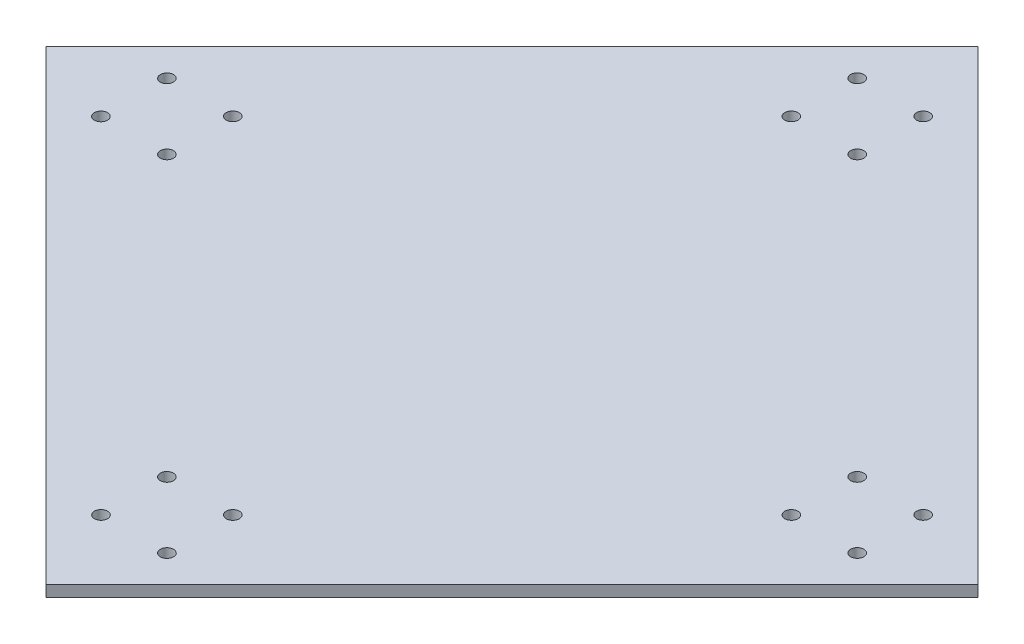
from build123d import *

# Parameters (mm, degrees)
SKETCH3_R           = 1500
BOSS_EXTRUDE2_DEPTH = 2500


with BuildPart() as part:
    # Sketch3 → Boss-Extrude2 (new body)
    with BuildSketch(Plane(origin=(0, 0, 0), x_dir=(1, 0, 0), z_dir=(0, 1, 0))):
        Polygon((94457.392609736, 188109.713508362), (200523.409787719, 82043.696330379), (94472.169284797, -24037.095464325), (-11608.622509908, 82043.696330379), align=None)
        with Locations((23406.152106819, 74543.696330375)):
            Circle(SKETCH3_R, mode=Mode.SUBTRACT)
        with Locations((8406.152106819, 89543.696330375)):
            Circle(SKETCH3_R, mode=Mode.SUBTRACT)
        with Locations((8406.152106819, 74528.921713652)):
            Circle(SKETCH3_R, mode=Mode.SUBTRACT)
        with Locations((101972.169284806, 10977.679152396)):
            Circle(SKETCH3_R, mode=Mode.SUBTRACT)
        with Locations((86972.169284806, -4022.320847604)):
            Circle(SKETCH3_R, mode=Mode.SUBTRACT)
        with Locations((101986.943901529, -4022.320847604)):
            Circle(SKETCH3_R, mode=Mode.SUBTRACT)
        with Locations((165538.186462784, 89543.696330384)):
            Circle(SKETCH3_R, mode=Mode.SUBTRACT)
        with Locations((180538.186462784, 74543.696330384)):
            Circle(SKETCH3_R, mode=Mode.SUBTRACT)
        with Locations((180538.186462784, 89558.470947106)):
            Circle(SKETCH3_R, mode=Mode.SUBTRACT)
        with Locations((23406.152106818, 89543.696330376)):
            Circle(SKETCH3_R, mode=Mode.SUBTRACT)
        with Locations((86972.169284804, 10977.679152397)):
            Circle(SKETCH3_R, mode=Mode.SUBTRACT)
        with Locations((165538.186462783, 74543.696330383)):
            Circle(SKETCH3_R, mode=Mode.SUBTRACT)
        with Locations((86972.169284797, 153109.713508362)):
            Circle(SKETCH3_R, mode=Mode.SUBTRACT)
        with Locations((101972.169284797, 153109.713508362)):
            Circle(SKETCH3_R, mode=Mode.SUBTRACT)
        with Locations((101972.169284797, 168109.713508362)):
            Circle(SKETCH3_R, mode=Mode.SUBTRACT)
        with Locations((86957.394668074, 168109.713508362)):
            Circle(SKETCH3_R, mode=Mode.SUBTRACT)
    extrude(amount=BOSS_EXTRUDE2_DEPTH)


solid = part.part
